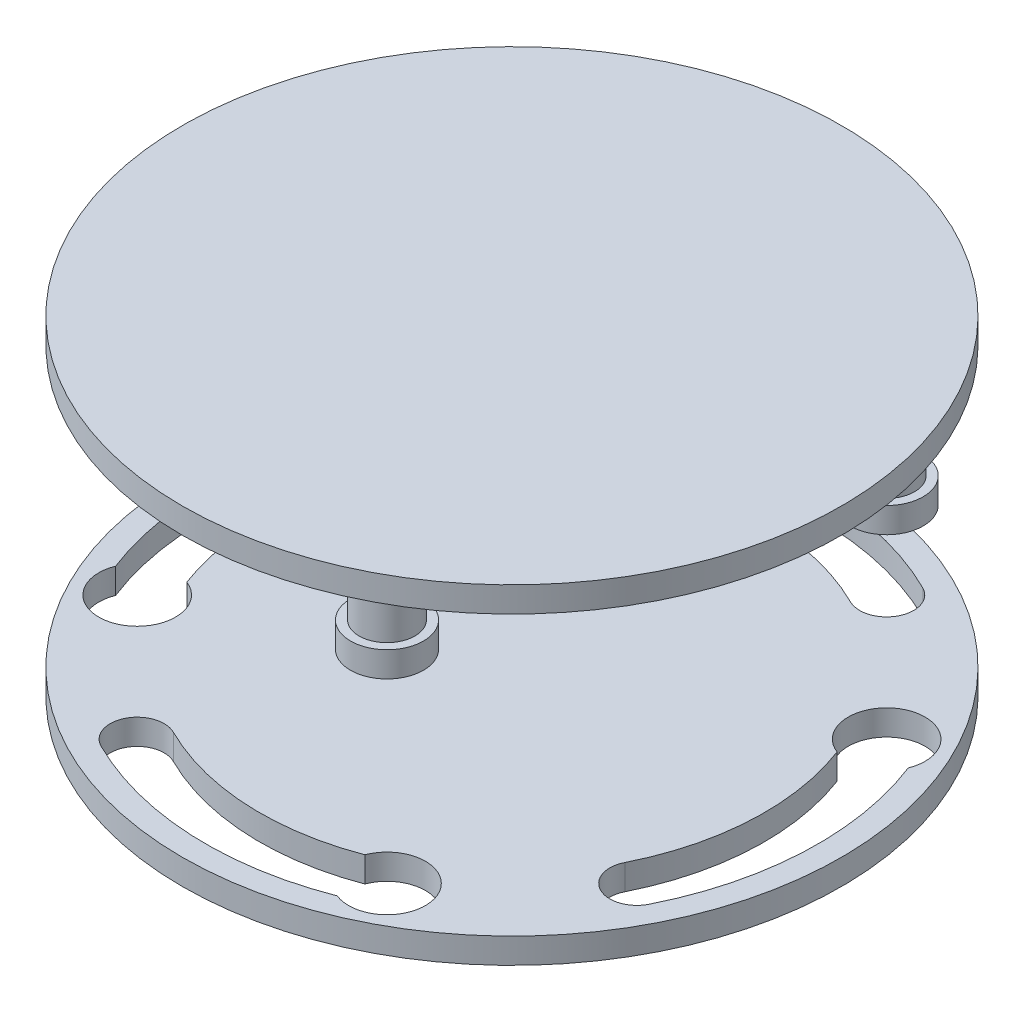
from build123d import *

# Parameters (mm, degrees)
SKETCH1_R            = 65
BOSS_EXTRUDE1_DEPTH  = 5
CUT_EXTRUDE2_DEPTH   = 5
SKETCH10_R           = 65
BOSS_EXTRUDE3_DEPTH  = 5
SKETCH14_R           = 5.5
BOSS_EXTRUDE4_DEPTH  = 10
SKETCH18_R           = 7.2
BOSS_EXTRUDE5_DEPTH  = 5
SKETCH21_R           = 5.5
BOSS_EXTRUDE6_DEPTH  = 10
SKETCH25_R           = 7.2
BOSS_EXTRUDE7_DEPTH  = 5
SKETCH27_R           = 5.5
BOSS_EXTRUDE9_DEPTH  = 10
SKETCH28_R           = 7.2
BOSS_EXTRUDE10_DEPTH = 5
SKETCH29_R           = 4
BOSS_EXTRUDE11_DEPTH = 5
SKETCH32_R           = 1
CUT_EXTRUDE4_DEPTH   = 5


with BuildPart() as part:
    # Sketch1 → Boss-Extrude1 (new body)
    with BuildSketch(Plane(origin=(0, 0, 0), x_dir=(1, 0, 0), z_dir=(0, 1, 0))):
        Circle(SKETCH1_R)
    extrude(amount=BOSS_EXTRUDE1_DEPTH)

    # Sketch2 → Cut-Extrude2 (cut)
    with BuildSketch(Plane(origin=(0, 5, 0), x_dir=(1, 0, 0), z_dir=(0, 1, 0))):
        with BuildLine():
            ThreePointArc((-54.028155023, 27.014077511), (-60.339208175, 2.825221378), (-56.315967651, -21.847510303))
            ThreePointArc((-56.315967651, -21.847510303), (-46.21967139, -31.570094031), (-46.569142204, -17.557895678))
            ThreePointArc((-46.569142204, -17.557895678), (-49.703000748, 2.564453724), (-44.514848815, 22.257424407))
            ThreePointArc((-44.514848815, 22.257424407), (-46.893175367, 29.392404063), (-54.028155023, 27.014077511))
        make_face()
        with BuildLine():
            ThreePointArc((46.569142204, 17.557895678), (49.703000748, -2.564453724), (44.514848815, -22.257424407))
            ThreePointArc((44.514848815, -22.257424407), (46.893175367, -29.392404063), (54.028155023, -27.014077511))
            ThreePointArc((54.028155023, -27.014077511), (60.339208175, -2.825221378), (56.315967651, 21.847510303))
            ThreePointArc((56.315967651, 21.847510303), (46.21967139, 31.570094031), (46.569142204, 17.557895678))
        make_face()
        with BuildLine():
            ThreePointArc((-17.557895678, 46.569142204), (2.564453724, 49.703000748), (22.257424407, 44.514848815))
            ThreePointArc((22.257424407, 44.514848815), (29.392404063, 46.893175367), (27.014077511, 54.028155023))
            ThreePointArc((27.014077511, 54.028155023), (2.825221378, 60.339208175), (-21.847510303, 56.315967651))
            ThreePointArc((-21.847510303, 56.315967651), (-31.570094031, 46.21967139), (-17.557895678, 46.569142204))
        make_face()
        with BuildLine():
            ThreePointArc((17.557895678, -46.569142204), (-2.564453724, -49.703000748), (-22.257424407, -44.514848815))
            ThreePointArc((-22.257424407, -44.514848815), (-29.392404063, -46.893175367), (-27.014077511, -54.028155023))
            ThreePointArc((-27.014077511, -54.028155023), (-2.825221378, -60.339208175), (21.847510303, -56.315967651))
            ThreePointArc((21.847510303, -56.315967651), (31.570094031, -46.21967139), (17.557895678, -46.569142204))
        make_face()
    extrude(amount=-CUT_EXTRUDE2_DEPTH, mode=Mode.SUBTRACT)

    # Sketch29 → Boss-Extrude11 (add)
    with BuildSketch(Plane.XZ):
        Circle(SKETCH29_R)
    extrude(amount=BOSS_EXTRUDE11_DEPTH)

    # Sketch32 → Cut-Extrude4 (cut)
    with BuildSketch(Plane.XZ.offset(5)):
        Circle(SKETCH32_R)
    extrude(amount=-CUT_EXTRUDE4_DEPTH, mode=Mode.SUBTRACT)


with BuildPart() as body_2:
    # Sketch10 → Boss-Extrude3 (new body)
    with BuildSketch(Plane(origin=(0, 60, 0), x_dir=(1, 0, 0), z_dir=(0, 1, 0))):
        Circle(SKETCH10_R)
    extrude(amount=BOSS_EXTRUDE3_DEPTH)

    # Sketch14 → Boss-Extrude4 (add)
    with BuildSketch(Plane.XZ.offset(-60)):
        with Locations((-24.637923521, -49.295690328)):
            Circle(SKETCH14_R)
    extrude(amount=BOSS_EXTRUDE4_DEPTH)

    # Sketch18 → Boss-Extrude5 (add)
    with BuildSketch(Plane.XZ.offset(-50)):
        with Locations((-24.637923521, -49.295690328)):
            Circle(SKETCH18_R)
    extrude(amount=BOSS_EXTRUDE5_DEPTH)

    # Sketch21 → Boss-Extrude6 (add)
    with BuildSketch(Plane(origin=(0, 60, 0), x_dir=(1, 0, 0), z_dir=(0, 1, 0))):
        with Locations((-49.272878351, -24.629663863)):
            Circle(SKETCH21_R)
    extrude(amount=-BOSS_EXTRUDE6_DEPTH)

    # Sketch25 → Boss-Extrude7 (add)
    with BuildSketch(Plane.XZ.offset(-50)):
        with Locations((-49.253550208, 24.648775945)):
            Circle(SKETCH25_R)
    extrude(amount=BOSS_EXTRUDE7_DEPTH)

    # Sketch27 → Boss-Extrude9 (add)
    with BuildSketch(Plane(origin=(0, 60, 0), x_dir=(1, 0, 0), z_dir=(0, 1, 0))):
        with Locations((49.271501919, 24.635750959)):
            Circle(SKETCH27_R)
        with Locations((24.635750959, -49.271501919)):
            Circle(SKETCH27_R)
    extrude(amount=-BOSS_EXTRUDE9_DEPTH)

    # Sketch28 → Boss-Extrude10 (add)
    with BuildSketch(Plane.XZ.offset(-50)):
        with Locations((49.271501919, -24.635750959)):
            Circle(SKETCH28_R)
        with Locations((24.635750959, 49.271501919)):
            Circle(SKETCH28_R)
    extrude(amount=BOSS_EXTRUDE10_DEPTH)


solid = Compound([part.part, body_2.part])
